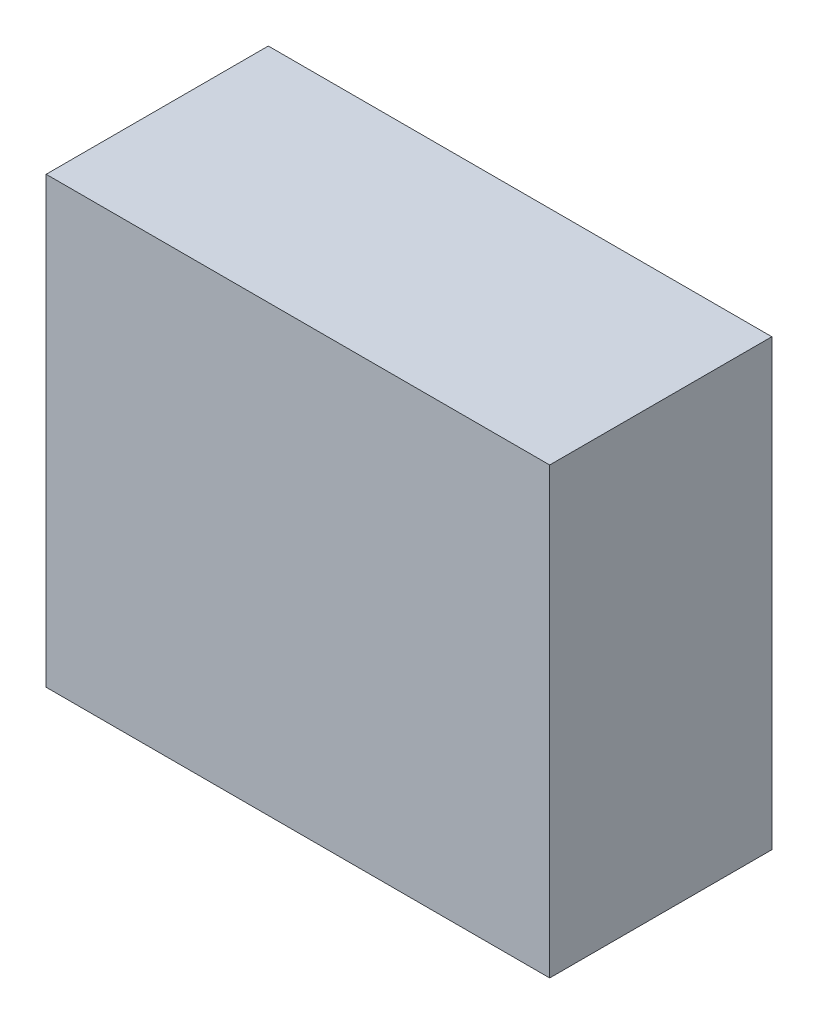
from build123d import *

# Parameters (mm, degrees)
SKETCH1_W           = 34
SKETCH1_H           = 30
BOSS_EXTRUDE1_DEPTH = 15
SKETCH2_R           = 2.1
CUT_EXTRUDE1_DEPTH  = 6
CHAMFER1_SIZE       = 1


with BuildPart() as part:
    # Sketch1 → Boss-Extrude1 (new body)
    with BuildSketch(Plane.XY):
        Rectangle(SKETCH1_W, SKETCH1_H)
    extrude(amount=BOSS_EXTRUDE1_DEPTH)

    # Sketch2 → Cut-Extrude1 (cut)
    with BuildSketch(Plane(origin=(0, 0, 0), x_dir=(-1, 0, 0), z_dir=(0, 0, -1))):
        with Locations((12, -9)):
            Circle(SKETCH2_R)
        with Locations((12, 9)):
            Circle(SKETCH2_R)
        with Locations((-12, 9)):
            Circle(SKETCH2_R)
        with Locations((-12, -9)):
            Circle(SKETCH2_R)
    extrude(amount=-CUT_EXTRUDE1_DEPTH, mode=Mode.SUBTRACT)

    # Chamfer1
    chamfer1_edges = [part.edges().sort_by_distance(p)[0] for p in [
        (14.1, -9, 0),
        (14.1, 9, 0),
        (-9.9, 9, 0),
        (-9.9, -9, 0),
    ]]
    chamfer(chamfer1_edges, length=CHAMFER1_SIZE)


solid = part.part
